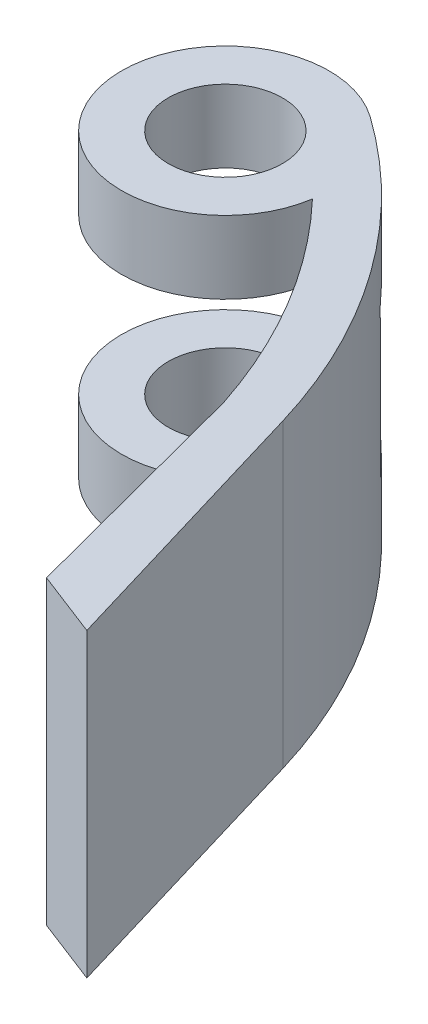
from build123d import *

# Parameters (mm, degrees)
SKETCH2_R                = 5.5
BOSS_EXTRUDE1_DEPTH      = 29
SKETCH3_R                = 12
CUT_EXTRUDE2_DEPTH       = 14
SKETCH5_R                = 4
SKETCH5_R_2              = 2
BOSS_EXTRUDE2_DEPTH      = 1
BOSS_EXTRUDE2_DEPTH_BACK = 1
SKETCH6_R                = 12
CUT_EXTRUDE3_DEPTH       = 1


with BuildPart() as part:
    # Sketch2 → Boss-Extrude1 (new body)
    with BuildSketch(Plane(origin=(0, 0, 0), x_dir=(1, 0, 0), z_dir=(0, 1, 0))):
        with BuildLine():
            ThreePointArc((50.009794046, 41.311227393), (41.887297641, 57.884223181), (28.818508763, 70.916716976))
            ThreePointArc((28.818508763, 70.916716976), (13.814285335, 58.864855467), (32.908133208, 61.2729792))
            ThreePointArc((32.908133208, 61.2729792), (40.45496434, 51.34849017), (45.618872448, 40.00017771))
            Line((45.618872448, 40.00017771), (51.710808427, 16.848599978))
            Line((51.710808427, 16.848599978), (58.045348615, 14.398829975))
            Line((58.045348615, 14.398829975), (50.009794046, 41.311227393))
        make_face()
        with Locations((23.020672213, 62.769012309)):
            Circle(SKETCH2_R, mode=Mode.SUBTRACT)
    extrude(amount=BOSS_EXTRUDE1_DEPTH)

    # Sketch3 → Cut-Extrude2 (cut)
    with BuildSketch(Plane(origin=(0, 7, 0), x_dir=(-1, 0, 0), z_dir=(0, -1, 0))):
        Polygon((-39.772770103, 64.267022184), (-15.893793884, 42.042250192), (-0.061179653, 60.713204229), (-23.940155872, 82.937976221), align=None)
        with Locations((-23.020672213, 62.769012309)):
            Circle(SKETCH3_R, mode=Mode.SUBTRACT)
        with BuildLine():
            ThreePointArc((-11.020672213, 62.769012309), (-24.725973403, 74.647225468), (-34.535996855, 59.393023803))
            Line((-34.535996855, 59.393023803), (-25.562701432, 51.041348968))
            ThreePointArc((-25.562701432, 51.041348968), (-15.487557008, 53.428125022), (-11.020672213, 62.769012309))
        make_face()
        with BuildLine():
            Line((-25.562701432, 51.041348968), (-34.535996855, 59.393023803))
            ThreePointArc((-34.535996855, 59.393023803), (-31.196240544, 53.984931113), (-25.562701432, 51.041348968))
        make_face()
    extrude(amount=-CUT_EXTRUDE2_DEPTH, mode=Mode.SUBTRACT)

    # Sketch5 → Boss-Extrude2 (add, two sides)
    with BuildSketch(Plane(origin=(0, 14.5, 0), x_dir=(-1, 0, 0), z_dir=(0, -1, 0))) as boss_extrude2_sk:
        with Locations((-48.811207054, 27.868142339)):
            Circle(SKETCH5_R)
        with Locations((-48.811207054, 27.868142339)):
            Circle(SKETCH5_R_2, mode=Mode.SUBTRACT)
    extrude(amount=BOSS_EXTRUDE2_DEPTH)
    extrude(boss_extrude2_sk.sketch, amount=-BOSS_EXTRUDE2_DEPTH_BACK)

    # Sketch6 → Cut-Extrude3 (cut)
    with BuildSketch(Plane(origin=(0, 22, 0), x_dir=(1, 0, 0), z_dir=(0, 1, 0))):
        Polygon((39.538971905, 63.831822433), (17.017916797, 43.859723681), (2.667298857, 64.33781743), (24.409587021, 83.619290887), align=None)
        with Locations((23.020672213, 62.769012309)):
            Circle(SKETCH6_R, mode=Mode.SUBTRACT)
        with BuildLine():
            ThreePointArc((24.993041452, 50.932215463), (30.982651495, 53.790878543), (34.536814652, 59.395814522))
            Line((34.536814652, 59.395814522), (24.993041452, 50.932215463))
        make_face()
        with BuildLine():
            Line((24.993041452, 50.932215463), (34.536814652, 59.395814522))
            ThreePointArc((34.536814652, 59.395814522), (34.899091916, 61.065150413), (35.020672213, 62.769012309))
            ThreePointArc((35.020672213, 62.769012309), (13.86456958, 70.525672967), (24.993041452, 50.932215463))
        make_face()
    extrude(amount=-CUT_EXTRUDE3_DEPTH, mode=Mode.SUBTRACT)


solid = part.part
